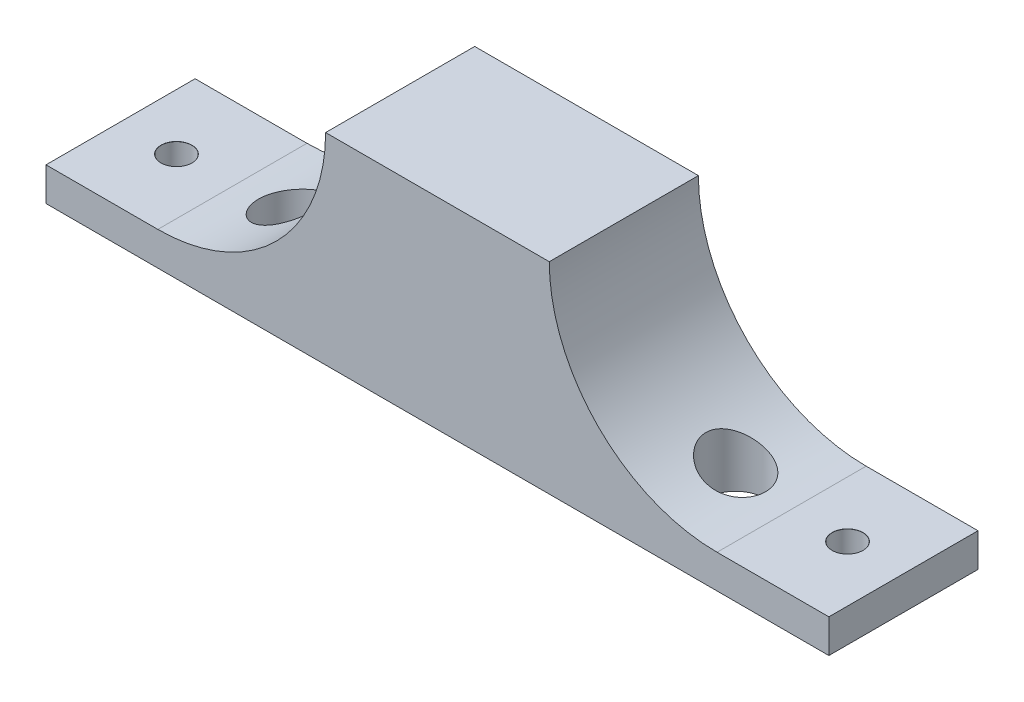
from build123d import *

# Parameters (mm, degrees)
SKETCH1_W                              = 60
SKETCH1_H                              = 40
BOSS_EXTRUDE1_DEPTH                    = 54
SKETCH3_W                              = 75
SKETCH3_H                              = 40
SKETCH3_R                              = 8
BOSS_EXTRUDE2_DEPTH                    = 54
CUT_EXTRUDE2_DEPTH                     = 60
TAP_DRILL_FOR_M8_HELICOIL1_D           = 8.25
TAP_DRILL_FOR_M8_HELICOIL1_CSINK_D     = 8.3
TAP_DRILL_FOR_M8_HELICOIL1_CSINK_ANGLE = 90


with BuildPart() as part:
    # Sketch1 → Boss-Extrude1 (new body)
    with BuildSketch(Plane(origin=(0, 0, 0), x_dir=(1, 0, 0), z_dir=(0, 1, 0))):
        with Locations((-30, -20)):
            Rectangle(SKETCH1_W, SKETCH1_H)
    extrude(amount=BOSS_EXTRUDE1_DEPTH)

    # Sketch3 → Boss-Extrude2 (add)
    with BuildSketch(Plane(origin=(0, 0, 0), x_dir=(1, 0, 0), z_dir=(0, 1, 0))):
        with Locations((37.5, -20)):
            Rectangle(SKETCH3_W, SKETCH3_H)
        with Locations((30, -20)):
            Circle(SKETCH3_R, mode=Mode.SUBTRACT)
    boss_extrude2 = extrude(amount=BOSS_EXTRUDE2_DEPTH)

    # Sketch4 → Cut-Extrude2 (cut)
    with BuildSketch(Plane.XY.offset(40)):
        with BuildLine():
            ThreePointArc((75, 20.458980338), (61.05699404, 11.962243847), (45, 9))
            Line((45, 9), (75, 9))
            Line((75, 9), (75, 20.458980338))
        make_face()
        with BuildLine():
            Line((45, 9), (45, 54))
            Line((45, 54), (0, 54))
            ThreePointArc((0, 54), (13.180194847, 22.180194847), (45, 9))
        make_face()
        with BuildLine():
            Line((75, 54), (45, 54))
            Line((45, 54), (45, 9))
            ThreePointArc((45, 9), (61.05699404, 11.962243847), (75, 20.458980338))
            Line((75, 20.458980338), (75, 54))
        make_face()
    cut_extrude2 = extrude(amount=-CUT_EXTRUDE2_DEPTH, mode=Mode.SUBTRACT)

    # Tap Drill for M8 Helicoil1 (through all)
    with Locations(Plane(origin=(0, 9, 0), x_dir=(1, 0, 0), z_dir=(0, 1, 0))):
        with Locations((60, -20)):
            tap_drill_for_m8_helicoil1 = CounterSinkHole(TAP_DRILL_FOR_M8_HELICOIL1_D / 2, TAP_DRILL_FOR_M8_HELICOIL1_CSINK_D / 2, counter_sink_angle=TAP_DRILL_FOR_M8_HELICOIL1_CSINK_ANGLE)

    # Mirror1: Boss-Extrude2, Cut-Extrude2, Tap Drill for M8 Helicoil1 across plane
    add(boss_extrude2.mirror(Plane(origin=(-30, 0, 0), x_dir=(0, 0, 1), z_dir=(1, 0, 0))))
    add(cut_extrude2.mirror(Plane(origin=(-30, 0, 0), x_dir=(0, 0, 1), z_dir=(1, 0, 0))), mode=Mode.SUBTRACT)
    add(tap_drill_for_m8_helicoil1.mirror(Plane(origin=(-30, 0, 0), x_dir=(0, 0, 1), z_dir=(1, 0, 0))), mode=Mode.SUBTRACT)


solid = part.part
